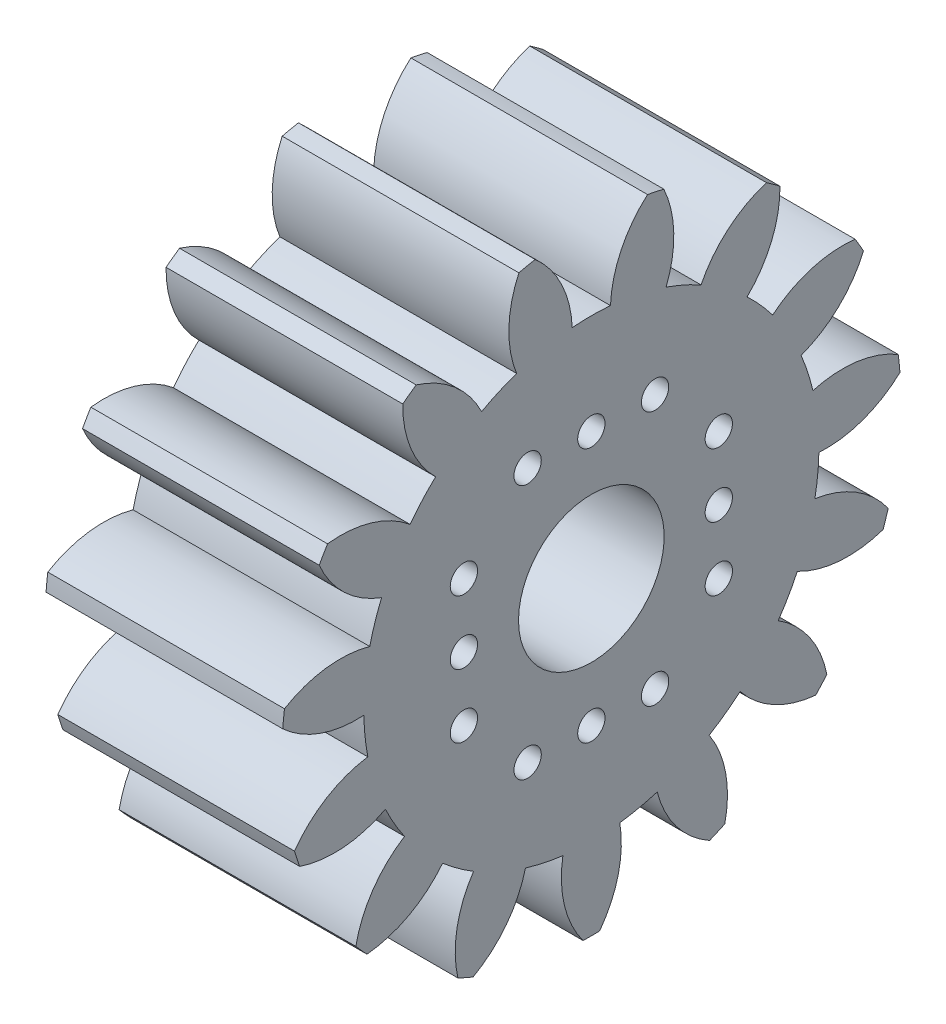
from build123d import *

# Parameters (mm, degrees)
BASPROSKE_W        = 13
BASPROSKE_H        = 17
TOOTHCUT_DEPTH     = 28.331300737
TEETHCUTS_COUNT    = 15
TEETHCUTS_ANGLE    = 336
BORSKE_R           = 4
BORE_DEPTH         = 50.0000508
SKETCH1_R          = 0.75
CUT_EXTRUDE1_DEPTH = 7
CIRPATTERN1_COUNT  = 4


with BuildPart() as part:
    # BasProSke → Base-Revolve (revolve)
    with BuildSketch(Plane(origin=(0, 0, 0), x_dir=(1, 0, 0), z_dir=(0, 1, 0)), mode=Mode.PRIVATE) as base_revolve_sk:
        with Locations((6.5, 8.5)):
            Rectangle(BASPROSKE_W, BASPROSKE_H)
    revolve(base_revolve_sk.sketch.rotate(Axis((-10, 0, 0), (1, 0, 0)), 180), axis=Axis((-10, 0, 0), (1, 0, 0)))

    # TooCutSke → ToothCut (cut, through all)
    with BuildSketch(Plane(origin=(0, 0, 0), x_dir=(0, 0, -1), z_dir=(1, 0, 0))):
        with BuildLine():
            ThreePointArc((1.050056448, 12.454813626), (0, 12.499), (-1.050056448, 12.454813626))
            ThreePointArc((-1.050056448, 12.454813626), (-1.638118106, 14.809604533), (-3.110934279, 16.73876737))
            ThreePointArc((-3.110934279, 16.73876737), (0, 17.0254), (3.110934279, 16.73876737))
            ThreePointArc((3.110934279, 16.73876737), (1.638118106, 14.809604533), (1.050056448, 12.454813626))
        make_face()
    toothcut = extrude(amount=TOOTHCUT_DEPTH, mode=Mode.SUBTRACT)

    # TeethCuts: ToothCut ×15 about axis
    teethcuts_axis = Axis((-10, 0, 0), (1, 0, 0))
    for i in range(1, TEETHCUTS_COUNT):
        add(toothcut.rotate(teethcuts_axis, i * TEETHCUTS_ANGLE / (TEETHCUTS_COUNT - 1)), mode=Mode.SUBTRACT)

    # BorSke → Bore (cut, symmetric)
    with BuildSketch(Plane(origin=(0, 0, 0), x_dir=(0, 0, -1), z_dir=(1, 0, 0))):
        with Locations(Location((0, 0, 0), (0, 0, 180))):
            Circle(BORSKE_R)
    extrude(amount=BORE_DEPTH, both=True, mode=Mode.SUBTRACT)

    # Sketch1 → Cut-Extrude1 (cut)
    with BuildSketch(Plane(origin=(13, 0, 0), x_dir=(0, 0, -1), z_dir=(1, 0, 0))):
        with Locations((-3.5, 7)):
            Circle(SKETCH1_R)
        with Locations((0, 7)):
            Circle(SKETCH1_R)
        with Locations((3.5, 7)):
            Circle(SKETCH1_R)
    cut_extrude1 = extrude(amount=-CUT_EXTRUDE1_DEPTH, mode=Mode.SUBTRACT)

    # CirPattern1: Cut-Extrude1 ×4 about axis
    cirpattern1_axis = Axis((0, 0, 0), (1, 0, 0))
    for i in range(1, CIRPATTERN1_COUNT):
        add(cut_extrude1.rotate(cirpattern1_axis, i * 360 / CIRPATTERN1_COUNT), mode=Mode.SUBTRACT)


solid = part.part
